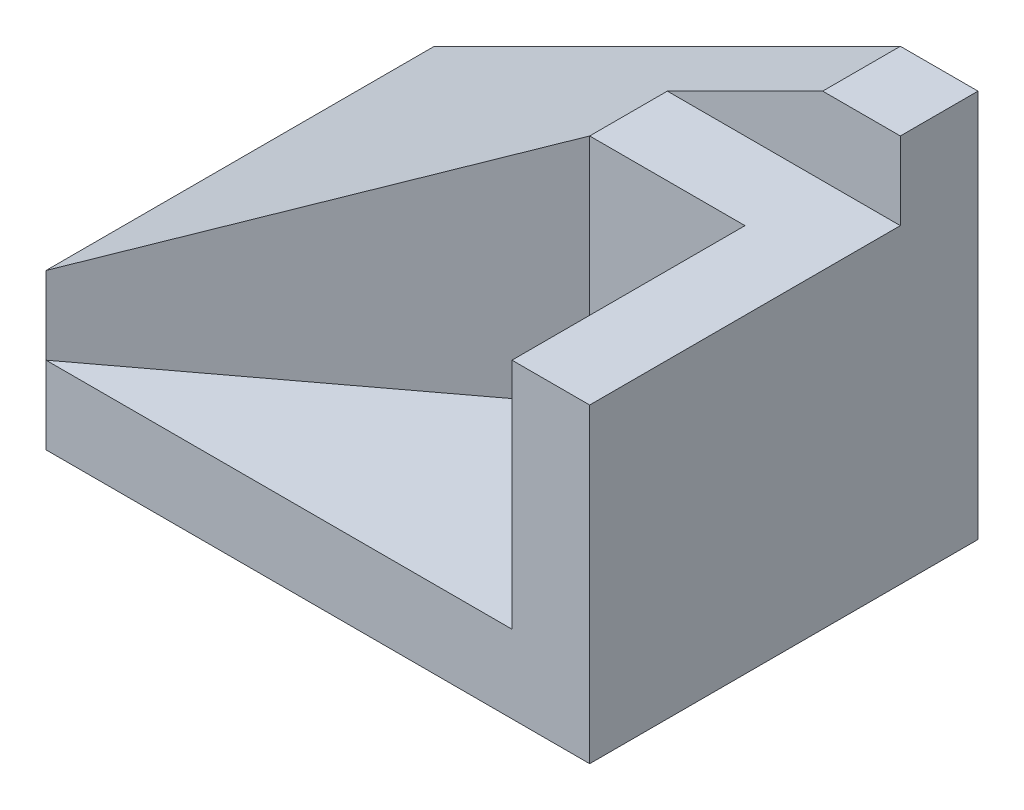
from build123d import *

# Parameters (mm, degrees)
SKETCH1_W           = 70
SKETCH1_H           = 50
BOSS_EXTRUDE1_DEPTH = 50
CUT_EXTRUDE1_DEPTH  = 50
SKETCH3_W           = 40
SKETCH3_H           = 10
CUT_EXTRUDE2_DEPTH  = 50
CUT_EXTRUDE3_DEPTH  = 30
BOSS_EXTRUDE2_DEPTH = 30
SKETCH9_W           = 20
SKETCH9_H           = 10
BOSS_EXTRUDE3_DEPTH = 5
CUT_EXTRUDE5_DEPTH  = 5
SKETCH15_W          = 70
SKETCH15_H          = 50
CUT_EXTRUDE10_DEPTH = 19
CUT_EXTRUDE11_DEPTH = 19
SKETCH18_W          = 67.082039325
SKETCH18_H          = 30
BOSS_EXTRUDE8_DEPTH = 10
SKETCH19_W          = 50
SKETCH19_H          = 20
CUT_EXTRUDE12_DEPTH = 10
SKETCH20_W          = 45
SKETCH20_H          = 76.778692576
CUT_EXTRUDE13_DEPTH = 28
CUT_EXTRUDE14_DEPTH = 28
SKETCH22_W          = 20
SKETCH22_H          = 10
CUT_EXTRUDE15_DEPTH = 30
CUT_EXTRUDE16_DEPTH = 10
CUT_EXTRUDE17_DEPTH = 10
CUT_EXTRUDE18_DEPTH = 10
CUT_EXTRUDE19_DEPTH = 5


with BuildPart() as part:
    # Sketch1 → Boss-Extrude1 (new body)
    with BuildSketch(Plane.XY):
        with Locations((35, 25)):
            Rectangle(SKETCH1_W, SKETCH1_H)
    extrude(amount=BOSS_EXTRUDE1_DEPTH)

    # Sketch2 → Cut-Extrude1 (cut)
    with BuildSketch(Plane.XY.offset(50)):
        Polygon((0, 50), (60, 50), (0, 20), align=None)
    extrude(amount=-CUT_EXTRUDE1_DEPTH, mode=Mode.SUBTRACT)

    # Sketch3 → Cut-Extrude2 (cut)
    with BuildSketch(Plane(origin=(70, 0, 0), x_dir=(0, 0, -1), z_dir=(1, 0, 0))):
        with Locations((-30, 45)):
            Rectangle(SKETCH3_W, SKETCH3_H)
    extrude(amount=-CUT_EXTRUDE2_DEPTH, mode=Mode.SUBTRACT)

    # Sketch4 → Cut-Extrude3 (cut)
    with BuildSketch(Plane.XY.offset(50)):
        Polygon((60, 10), (60, 40), (40, 40), (0, 20), (0, 10), align=None)
    extrude(amount=-CUT_EXTRUDE3_DEPTH, mode=Mode.SUBTRACT)

    # Sketch8 → Boss-Extrude2 (add)
    with BuildSketch(Plane(origin=(-8, 16, 0), x_dir=(0.894427191, 0.447213595, 0), z_dir=(-0.447213595, 0.894427191, 0))):
        Polygon((8.94427191, -20), (8.94427191, -40), (53.66563146, -20), align=None)
    extrude(amount=-BOSS_EXTRUDE2_DEPTH)

    # Sketch9 → Boss-Extrude3 (add)
    with BuildSketch(Plane.ZY):
        with Locations((30, 15)):
            Rectangle(SKETCH9_W, SKETCH9_H)
    extrude(amount=-BOSS_EXTRUDE3_DEPTH)

    # Sketch10 → Cut-Extrude5 (cut)
    with BuildSketch(Plane.XZ):
        Polygon((10, 40), (27.082039325, 33.16718427), (27.082039325, 20), (10, 20), align=None)
    extrude(amount=CUT_EXTRUDE5_DEPTH, mode=Mode.SUBTRACT)

    # Sketch15 → Cut-Extrude10 (cut)
    with BuildSketch(Plane(origin=(0, 0, 0), x_dir=(-1, 0, 0), z_dir=(0, -1, 0))):
        with Locations((-35, -25)):
            Rectangle(SKETCH15_W, SKETCH15_H)
    extrude(amount=CUT_EXTRUDE10_DEPTH, mode=Mode.SUBTRACT)

    # Sketch16 → Cut-Extrude11 (cut)
    with BuildSketch(Plane(origin=(14.666666667, 7.333333333, 36.666666667), x_dir=(0.930949336, -0.071611487, -0.358057437), z_dir=(0.365148372, 0.182574186, 0.912870929))):
        Polygon((-15.754527229, 11.766968108), (-10.383665674, 12.159200379), (-10.383665674, 1.961161351), (-16.527761833, 3.611754734), align=None)
    extrude(amount=CUT_EXTRUDE11_DEPTH, mode=Mode.SUBTRACT)

    # Sketch18 → Boss-Extrude8 (add)
    with BuildSketch(Plane(origin=(20, 0, 40), x_dir=(0.894427191, 0, -0.447213595), z_dir=(0.447213595, 0, 0.894427191))):
        with Locations((11.180339888, 25)):
            Rectangle(SKETCH18_W, SKETCH18_H)
    extrude(amount=-BOSS_EXTRUDE8_DEPTH)

    # Sketch19 → Cut-Extrude12 (cut)
    with BuildSketch(Plane.ZY):
        with Locations((25, 10)):
            Rectangle(SKETCH19_W, SKETCH19_H)
    extrude(amount=CUT_EXTRUDE12_DEPTH, mode=Mode.SUBTRACT)

    # Sketch20 → Cut-Extrude13 (cut)
    with BuildSketch(Plane(origin=(-8, 16, 0), x_dir=(0.894427191, 0.447213595, 0), z_dir=(-0.447213595, 0.894427191, 0))):
        with Locations((31.44427191, -38.389346288)):
            Rectangle(SKETCH20_W, SKETCH20_H)
    extrude(amount=CUT_EXTRUDE13_DEPTH, mode=Mode.SUBTRACT)

    # Sketch21 → Cut-Extrude14 (cut)
    with BuildSketch(Plane(origin=(8, 4, 0), x_dir=(0, 0, -1), z_dir=(0.894427191, 0.447213595, 0))):
        Polygon((-50, 17.88854382), (-38.819660113, 17.88854382), (-41.05572809, 27.88854382), align=None)
    extrude(amount=-CUT_EXTRUDE14_DEPTH, mode=Mode.SUBTRACT)

    # Sketch22 → Cut-Extrude15 (cut)
    with BuildSketch(Plane(origin=(0, 40, 0), x_dir=(1, 0, 0), z_dir=(0, 1, 0))):
        with Locations((50, -25)):
            Rectangle(SKETCH22_W, SKETCH22_H)
    extrude(amount=-CUT_EXTRUDE15_DEPTH, mode=Mode.SUBTRACT)

    # Sketch23 → Cut-Extrude16 (cut)
    with BuildSketch(Plane(origin=(24, 0, 32), x_dir=(0.8, 0, -0.6), z_dir=(0.6, 0, 0.8))):
        Polygon((20, 40), (-30, 20), (-30, 10), (20, 10), align=None)
    extrude(amount=CUT_EXTRUDE16_DEPTH, mode=Mode.SUBTRACT)

    # Sketch24 → Cut-Extrude17 (cut)
    with BuildSketch(Plane(origin=(-8.827586207, 27.586206897, 6.620689655), x_dir=(0.954842468, 0.288908462, 0.069338031), z_dir=(0.297112541, -0.928476691, -0.222834406))):
        Polygon((51.136797811, 10.112827941), (51.136797811, 20.396796046), (9.245070791, 43.95190605), align=None)
    extrude(amount=-CUT_EXTRUDE17_DEPTH, mode=Mode.SUBTRACT)

    # Sketch25 → Cut-Extrude18 (cut)
    with BuildSketch(Plane(origin=(40, 0, 0), x_dir=(0, 0, -1), z_dir=(1, 0, 0))):
        Polygon((-30, 40), (-20, 40), (-30, 37.6), align=None)
    extrude(amount=-CUT_EXTRUDE18_DEPTH, mode=Mode.SUBTRACT)

    # Sketch26 → Cut-Extrude19 (cut)
    with BuildSketch(Plane(origin=(20, 0, 40), x_dir=(0.894427191, 0, -0.447213595), z_dir=(0.447213595, 0, 0.894427191))):
        Polygon((21.632516526, 39.674355495), (22.360679775, 40), (22.360679775, 37.6), align=None)
    extrude(amount=-CUT_EXTRUDE19_DEPTH, mode=Mode.SUBTRACT)


solid = part.part
